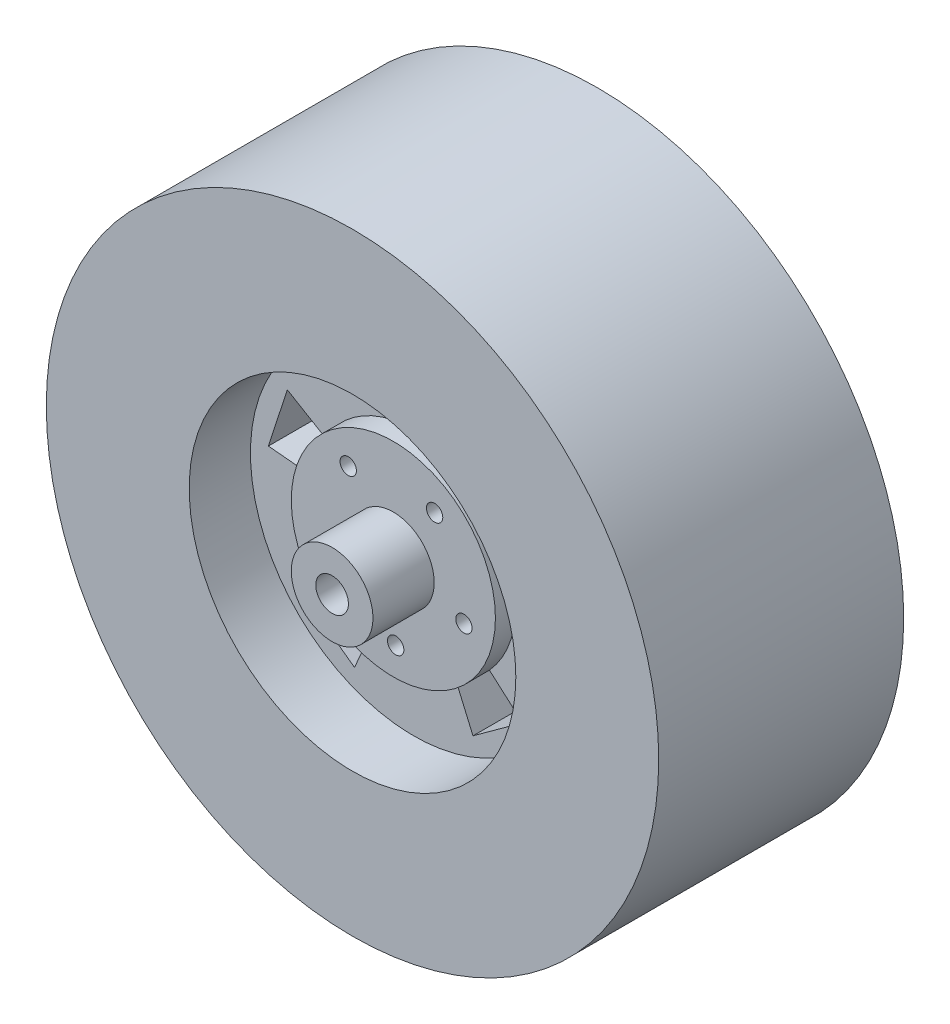
from build123d import *

# Parameters (mm, degrees)
SKETCH1_R                = 75
SKETCH1_R_2              = 40
BOSS_EXTRUDE1_DEPTH      = 60
BOSS_EXTRUDE2_DEPTH      = 15
BOSS_EXTRUDE2_DEPTH_BACK = 15
BOSS_EXTRUDE2_START      = 30
SKETCH2_R                = 40
SKETCH2_R_2              = 10
SKETCH5_R                = 25
SKETCH5_R_2              = 2
SKETCH5_R_3              = 4
BOSS_EXTRUDE4_DEPTH      = 5
BOSS_EXTRUDE5_START      = -35
SKETCH5_2_R              = 25
SKETCH5_2_R_2            = 2
SKETCH5_2_R_3            = 4
BOSS_EXTRUDE5_DEPTH      = 5
BOSS_EXTRUDE6_START      = 15
SKETCH6_R                = 10
SKETCH6_R_2              = 4
BOSS_EXTRUDE6_DEPTH      = 15
BOSS_EXTRUDE7_START      = -40
SKETCH6_2_R              = 10
SKETCH6_2_R_2            = 4
BOSS_EXTRUDE7_DEPTH      = 15


with BuildPart() as part:
    # Sketch1 → Boss-Extrude1 (new body)
    with BuildSketch(Plane.XY):
        Circle(SKETCH1_R)
        Circle(SKETCH1_R_2, mode=Mode.SUBTRACT)
    extrude(amount=BOSS_EXTRUDE1_DEPTH)

    # Sketch2 → Boss-Extrude2 (add, two sides: drawn at the far end of the back side and taken through both)
    with BuildSketch(Plane.XY.offset(BOSS_EXTRUDE2_START - BOSS_EXTRUDE2_DEPTH_BACK)):
        Circle(SKETCH2_R)
        Circle(SKETCH2_R_2, mode=Mode.SUBTRACT)
        Polygon((7.5, 35), (-7.5, 35), (-3, 15), (3, 15), align=None, mode=Mode.SUBTRACT)
        Polygon((30.969350613, 17.948518675), (13.338796761, 7.488424465), (15.192898728, 1.782085367), (35.604605528, 3.682670931), align=None, mode=Mode.SUBTRACT)
        Polygon((26.640111288, -23.907205411), (11.243829768, -10.371899159), (6.389727801, -13.898610672), (14.504856372, -32.723984195), align=None, mode=Mode.SUBTRACT)
        Polygon((-14.504856372, -32.723984195), (-6.389727801, -13.898610673), (-11.243829768, -10.371899159), (-26.640111288, -23.907205411), align=None, mode=Mode.SUBTRACT)
        Polygon((-35.604605528, 3.682670931), (-15.192898728, 1.782085367), (-13.338796761, 7.488424465), (-30.969350613, 17.948518675), align=None, mode=Mode.SUBTRACT)
    extrude(amount=BOSS_EXTRUDE2_DEPTH + BOSS_EXTRUDE2_DEPTH_BACK)

    # Sketch5 → Boss-Extrude4 (add)
    with BuildSketch(Plane.XY.offset(45)):
        Circle(SKETCH5_R)
        with Locations((-11.040892983, 14.216141605)):
            Circle(SKETCH5_R_2, mode=Mode.SUBTRACT)
        with Locations((10.108530546, 14.893542567)):
            Circle(SKETCH5_R_2, mode=Mode.SUBTRACT)
        with Locations((17.288308436, -5.011426086)):
            Circle(SKETCH5_R_2, mode=Mode.SUBTRACT)
        with Locations((0.576231676, -17.990774221)):
            Circle(SKETCH5_R_2, mode=Mode.SUBTRACT)
        with Locations((-16.932177675, -6.107483866)):
            Circle(SKETCH5_R_2, mode=Mode.SUBTRACT)
        Circle(SKETCH5_R_3, mode=Mode.SUBTRACT)
    extrude(amount=BOSS_EXTRUDE4_DEPTH)

    # Sketch5_2 → Boss-Extrude5 (add)
    with BuildSketch(Plane.XY.offset(45).offset(BOSS_EXTRUDE5_START)):
        Circle(SKETCH5_2_R)
        with Locations((-11.040892983, 14.216141605)):
            Circle(SKETCH5_2_R_2, mode=Mode.SUBTRACT)
        with Locations((10.108530546, 14.893542567)):
            Circle(SKETCH5_2_R_2, mode=Mode.SUBTRACT)
        with Locations((17.288308436, -5.011426086)):
            Circle(SKETCH5_2_R_2, mode=Mode.SUBTRACT)
        with Locations((0.576231676, -17.990774221)):
            Circle(SKETCH5_2_R_2, mode=Mode.SUBTRACT)
        with Locations((-16.932177675, -6.107483866)):
            Circle(SKETCH5_2_R_2, mode=Mode.SUBTRACT)
        Circle(SKETCH5_2_R_3, mode=Mode.SUBTRACT)
    extrude(amount=BOSS_EXTRUDE5_DEPTH)

    # Sketch6 → Boss-Extrude6 (add)
    with BuildSketch(Plane(origin=(0, 0, 10), x_dir=(-1, 0, 0), z_dir=(0, 0, -1)).offset(BOSS_EXTRUDE6_START)):
        Circle(SKETCH6_R)
        Circle(SKETCH6_R_2, mode=Mode.SUBTRACT)
    extrude(amount=-BOSS_EXTRUDE6_DEPTH)

    # Sketch6_2 → Boss-Extrude7 (add)
    with BuildSketch(Plane(origin=(0, 0, 10), x_dir=(-1, 0, 0), z_dir=(0, 0, -1)).offset(BOSS_EXTRUDE7_START)):
        Circle(SKETCH6_2_R)
        Circle(SKETCH6_2_R_2, mode=Mode.SUBTRACT)
    extrude(amount=-BOSS_EXTRUDE7_DEPTH)


solid = part.part
